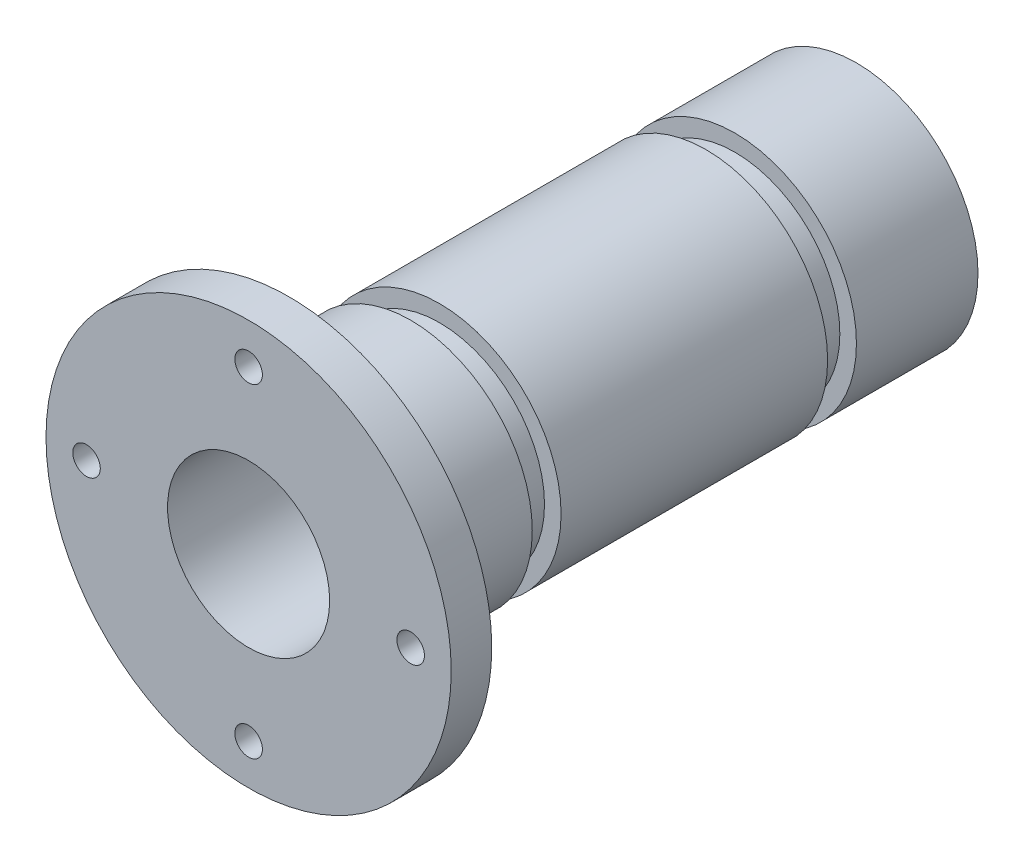
from build123d import *

# Parameters (mm, degrees)
SKETCH1_R           = 15
SKETCH1_R_2         = 10
BOSS_EXTRUDE1_DEPTH = 35
SKETCH5_W           = 3.556
SKETCH5_H           = 2.046
SKETCH6_R           = 25
SKETCH6_R_2         = 10
BOSS_EXTRUDE2_DEPTH = 5
CIRPATTERN1_COUNT   = 4


with BuildPart() as part:
    # Sketch1 → Boss-Extrude1 (new body, symmetric)
    with BuildSketch(Plane.XY):
        Circle(SKETCH1_R)
        Circle(SKETCH1_R_2, mode=Mode.SUBTRACT)
    extrude(amount=BOSS_EXTRUDE1_DEPTH, both=True)

    # Sketch5 → Cut-Revolve1 (revolve, cut)
    with BuildSketch(Plane(origin=(0, 0, 0), x_dir=(0, 0, -1), z_dir=(1, 0, 0))):
        with Locations((-18.222, 13.977)):
            Rectangle(SKETCH5_W, SKETCH5_H)
    cut_revolve1 = revolve(axis=Axis((0, 0, 0), (0, 0, 1)), mode=Mode.SUBTRACT)

    # Mirror1: Cut-Revolve1 across plane
    add(cut_revolve1.mirror(Plane.XY), mode=Mode.SUBTRACT)

    # Sketch6 → Boss-Extrude2 (add)
    with BuildSketch(Plane.XY.offset(35)):
        Circle(SKETCH6_R)
        Circle(SKETCH6_R_2, mode=Mode.SUBTRACT)
    extrude(amount=BOSS_EXTRUDE2_DEPTH)

    # Sketch9 → M3 Clearance Hole1 (revolve, cut)
    with BuildSketch(Plane(origin=(20, 0, 40), x_dir=(0, -1, 0), z_dir=(1, 0, 0))):
        Polygon((0, 0), (0, 18.521463052), (1.7, 17.5), (1.7, 0), align=None)
    m3_clearance_hole1 = revolve(axis=Axis((20, 0, 46.35), (0, 0, -1)), mode=Mode.SUBTRACT)

    # CirPattern1: M3 Clearance Hole1 ×4 about axis
    cirpattern1_axis = Axis((0, 0, 0), (0, 0, 1))
    for i in range(1, CIRPATTERN1_COUNT):
        add(m3_clearance_hole1.rotate(cirpattern1_axis, i * 360 / CIRPATTERN1_COUNT), mode=Mode.SUBTRACT)


solid = part.part
